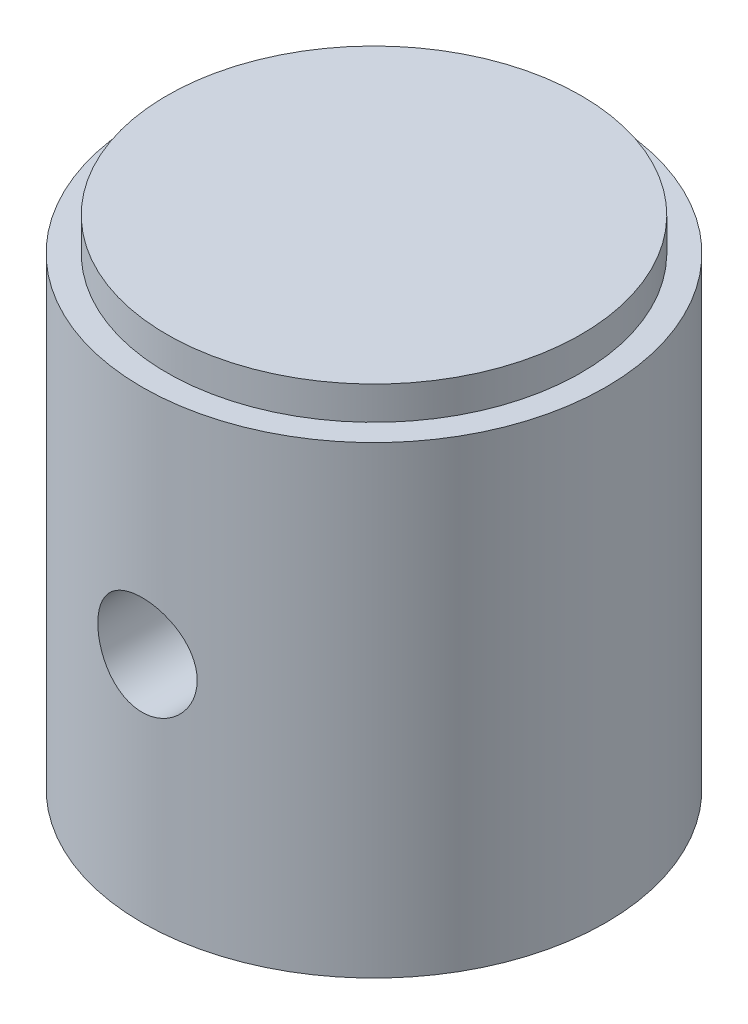
from build123d import *

# Parameters (mm, degrees)
SKETCH_2_R               = 1.5
CUT_EXTRUDE_1_DEPTH      = 8
CUT_EXTRUDE_1_DEPTH_BACK = 8


with BuildPart() as part:
    # Эскиз1 → Повернуть1 (revolve)
    with BuildSketch(Plane.XY):
        Polygon((-4.75, 3.983842258), (-4.75, 11), (0, 13.85408794), (0, 15), (-6.25, 15), (-6.25, 14), (-7, 14), (-7, 0), (-6.2, 0), align=None)
    revolve(axis=Axis((0, 0, 0), (0, 1, 0)))

    # Эскиз2 → Вырез-Вытянуть1 (cut, two sides)
    with BuildSketch(Plane.XY) as cut_extrude_1_sk:
        with Locations((0, 7)):
            Circle(SKETCH_2_R)
    extrude(amount=CUT_EXTRUDE_1_DEPTH, mode=Mode.SUBTRACT)
    extrude(cut_extrude_1_sk.sketch, amount=-CUT_EXTRUDE_1_DEPTH_BACK, mode=Mode.SUBTRACT)


solid = part.part
